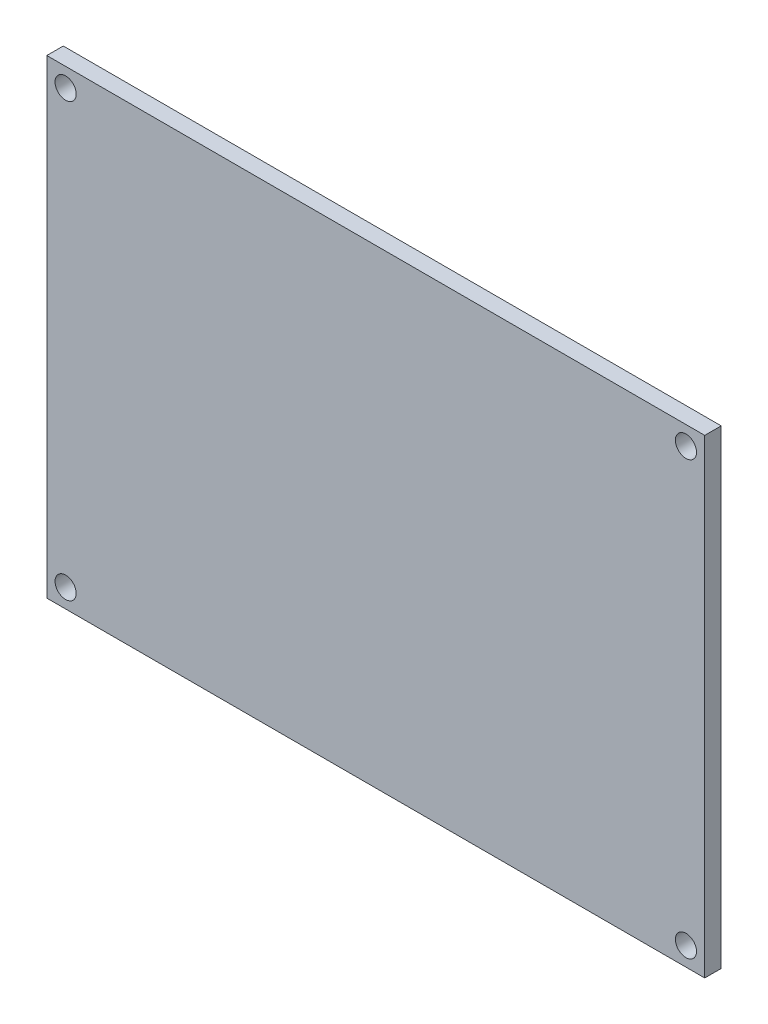
from build123d import *

# Parameters (mm, degrees)
SKETCH1_W           = 70
SKETCH1_H           = 50
SKETCH1_R           = 1.125
BOSS_EXTRUDE1_DEPTH = 1.75


with BuildPart() as part:
    # Sketch1 → Boss-Extrude1 (new body)
    with BuildSketch(Plane.XY):
        Rectangle(SKETCH1_W, SKETCH1_H)
        with Locations((-33, 23)):
            Circle(SKETCH1_R, mode=Mode.SUBTRACT)
        with Locations((33, 23)):
            Circle(SKETCH1_R, mode=Mode.SUBTRACT)
        with Locations((33, -23)):
            Circle(SKETCH1_R, mode=Mode.SUBTRACT)
        with Locations((-33, -23)):
            Circle(SKETCH1_R, mode=Mode.SUBTRACT)
    extrude(amount=BOSS_EXTRUDE1_DEPTH)


solid = part.part
